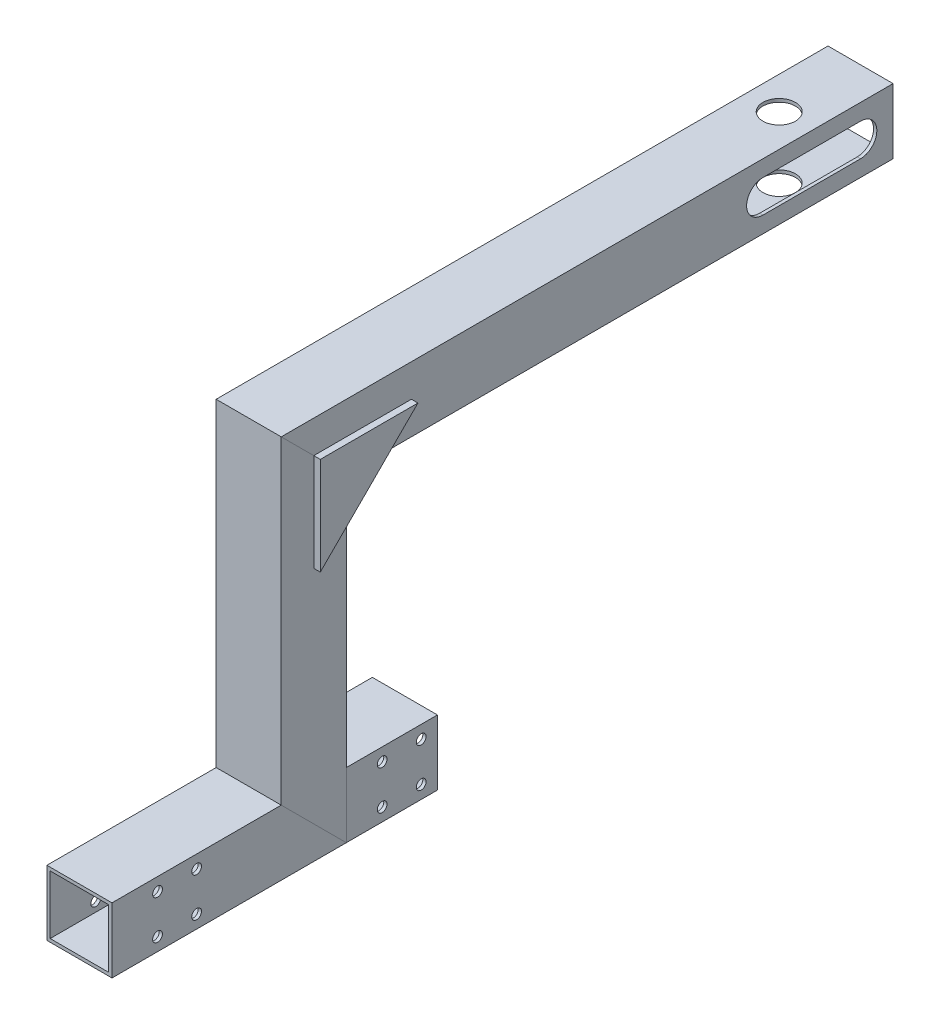
from build123d import *

# Parameters (mm, degrees)
SKETCH_14_W                = 20
SKETCH_14_H                = 20
SKETCH_14_W_2              = 18
SKETCH_14_H_2              = 18
F_20X20X1_1_DEPTH          = 77.142135624
SKETCH_14_ON_SEGMENT_2_W   = 20
SKETCH_14_ON_SEGMENT_2_H   = 20
SKETCH_14_ON_SEGMENT_2_W_2 = 18
SKETCH_14_ON_SEGMENT_2_H_2 = 18
F_20X20X1_1_2_DEPTH        = 128.284271247
SKETCH_14_ON_SEGMENT_3_W   = 20
SKETCH_14_ON_SEGMENT_3_H   = 20
SKETCH_14_ON_SEGMENT_3_W_2 = 18
SKETCH_14_ON_SEGMENT_3_H_2 = 18
F_20X20X1_1_3_DEPTH        = 193.142135624
SKETCH_14_ON_SEGMENT_4_W   = 20
SKETCH_14_ON_SEGMENT_4_H   = 20
SKETCH_14_ON_SEGMENT_4_W_2 = 18
SKETCH_14_ON_SEGMENT_4_H_2 = 18
F_20X20X1_1_4_DEPTH        = 64
SKETCH_12_R                = 1.5
CUT_EXTRUDE_1_DEPTH        = 264.939386981
CUT_EXTRUDE_3_DEPTH        = 264.939386981
CUT_EXTRUDE_4_DEPTH        = 260.43014474
EXTRUDE_1_DEPTH            = 2
EXTRUDE_2_DEPTH            = 2
SKETCH_17_R                = 1.5
CUT_EXTRUDE_7_DEPTH        = 265.098466486
SKETCH_23_W                = 25
SKETCH_23_H                = 20
CUT_EXTRUDE_8_DEPTH        = 265.098466486


with BuildPart() as part:
    # 草图14 → 铝管 20X20X1(1) (new body)
    with BuildSketch(Plane.YX):
        Rectangle(SKETCH_14_W, SKETCH_14_H)
        Rectangle(SKETCH_14_W_2, SKETCH_14_H_2, mode=Mode.SUBTRACT)
    extrude(amount=F_20X20X1_1_DEPTH)

    # 铝管 20X20X1(1) mitre 1
    split(bisect_by=Plane(origin=(0, 0, -62), x_dir=(1, 0, 0), z_dir=(0, -0.707106781, 0.707106781)), keep=Keep.TOP)

    # 草图12 → 切除-拉伸1 (cut, through all)
    with BuildSketch(Plane(origin=(10, 0, 0), x_dir=(0, 0, -1), z_dir=(1, 0, 0))):
        with Locations((14, 6)):
            Circle(SKETCH_12_R)
        with Locations((14, -6)):
            Circle(SKETCH_12_R)
        with Locations((26, -6)):
            Circle(SKETCH_12_R)
        with Locations((26, 6)):
            Circle(SKETCH_12_R)
    extrude(amount=-CUT_EXTRUDE_1_DEPTH, mode=Mode.SUBTRACT)


with BuildPart() as body_2:
    # 草图14 on segment 2 (carried to segment 2) → 20X20X1_1 2 (new body)
    with BuildSketch(Plane(origin=(0, -15.142135624, -62), x_dir=(0, 0, 1), z_dir=(0, 1, 0))):
        Rectangle(SKETCH_14_ON_SEGMENT_2_W, SKETCH_14_ON_SEGMENT_2_H)
        Rectangle(SKETCH_14_ON_SEGMENT_2_W_2, SKETCH_14_ON_SEGMENT_2_H_2, mode=Mode.SUBTRACT)
    extrude(amount=F_20X20X1_1_2_DEPTH)

    # 20X20X1_1 2 mitre 1
    split(bisect_by=Plane(origin=(0, 0, -62), x_dir=(-1, 0, 0), z_dir=(0, 0.707106781, -0.707106781)), keep=Keep.TOP)

    # 20X20X1_1 2 mitre 2
    split(bisect_by=Plane(origin=(0, 98, -62), x_dir=(1, 0, 0), z_dir=(0, -0.707106781, 0.707106781)), keep=Keep.TOP)


with BuildPart() as body_3:
    # 草图14 on segment 3 (carried to segment 3) → 20X20X1_1 3 (new body)
    with BuildSketch(Plane(origin=(0, 98, -46.857864376), x_dir=(0, 1, 0), z_dir=(0, 0, -1))):
        Rectangle(SKETCH_14_ON_SEGMENT_3_W, SKETCH_14_ON_SEGMENT_3_H)
        Rectangle(SKETCH_14_ON_SEGMENT_3_W_2, SKETCH_14_ON_SEGMENT_3_H_2, mode=Mode.SUBTRACT)
    extrude(amount=F_20X20X1_1_3_DEPTH)

    # 20X20X1_1 3 mitre 1
    split(bisect_by=Plane(origin=(0, 98, -62), x_dir=(-1, 0, 0), z_dir=(0, 0.707106781, -0.707106781)), keep=Keep.TOP)

    # 草图15 → 切除-拉伸3 (cut, through all)
    with BuildSketch(Plane(origin=(10, 0, 0), x_dir=(0, 0, -1), z_dir=(1, 0, 0))):
        with BuildLine():
            Line((200, 103), (230, 103))
            ThreePointArc((230, 103), (235, 98), (230, 93))
            Line((230, 93), (200, 93))
            ThreePointArc((200, 93), (195, 98), (200, 103))
        make_face()
    extrude(amount=-CUT_EXTRUDE_3_DEPTH, mode=Mode.SUBTRACT)

    # 草图16 → 切除-拉伸4 (cut, through all)
    with BuildSketch(Plane.XZ.offset(-88)):
        with BuildLine():
            ThreePointArc((-5, -215), (0, -220), (5, -215))
            Line((5, -215), (-5, -215))
        make_face()
        with BuildLine():
            Line((-5, -215), (5, -215))
            ThreePointArc((5, -215), (0, -210), (-5, -215))
        make_face()
    extrude(amount=-CUT_EXTRUDE_4_DEPTH, mode=Mode.SUBTRACT)


with BuildPart() as body_4:
    # 草图14 on segment 4 (carried to segment 4) → 20X20X1_1 4 (new body)
    with BuildSketch(Plane.YX.offset(61)):
        Rectangle(SKETCH_14_ON_SEGMENT_4_W, SKETCH_14_ON_SEGMENT_4_H)
        Rectangle(SKETCH_14_ON_SEGMENT_4_W_2, SKETCH_14_ON_SEGMENT_4_H_2, mode=Mode.SUBTRACT)
    extrude(amount=F_20X20X1_1_4_DEPTH)

    # 20X20X1_1 4 mitre 1
    split(bisect_by=Plane.YX.offset(72), keep=Keep.TOP)

    # 草图17 → 切除-拉伸7 (cut, through all)
    with BuildSketch(Plane(origin=(10, 0, 0), x_dir=(0, 0, -1), z_dir=(1, 0, 0))):
        with Locations((83, 6)):
            Circle(SKETCH_17_R)
        with Locations((95, 6)):
            Circle(SKETCH_17_R)
        with Locations((83, -6)):
            Circle(SKETCH_17_R)
        with Locations((95, -6)):
            Circle(SKETCH_17_R)
    extrude(amount=-CUT_EXTRUDE_7_DEPTH, mode=Mode.SUBTRACT)

    # 草图23 → 切除-拉伸8 (cut, through all)
    with BuildSketch(Plane(origin=(10, 0, 0), x_dir=(0, 0, -1), z_dir=(1, 0, 0))):
        with Locations((112.5, 0)):
            Rectangle(SKETCH_23_W, SKETCH_23_H)
    extrude(amount=-CUT_EXTRUDE_8_DEPTH, mode=Mode.SUBTRACT)


with BuildPart() as body_5:
    # 草图21 → 凸台-拉伸1 (new body)
    with BuildSketch(Plane(origin=(10, 0, 0), x_dir=(0, 0, -1), z_dir=(1, 0, 0))):
        Polygon((62, 98), (62, 68), (92, 98), align=None)
    extrude(amount=EXTRUDE_1_DEPTH)


with BuildPart() as body_6:
    # 草图22 → 凸台-拉伸2 (new body)
    with BuildSketch(Plane.ZY.offset(10)):
        Polygon((-62, 98), (-92, 98), (-62, 68), align=None)
    extrude(amount=EXTRUDE_2_DEPTH)


solid = Compound([part.part, body_2.part, body_3.part, body_4.part, body_5.part, body_6.part])
